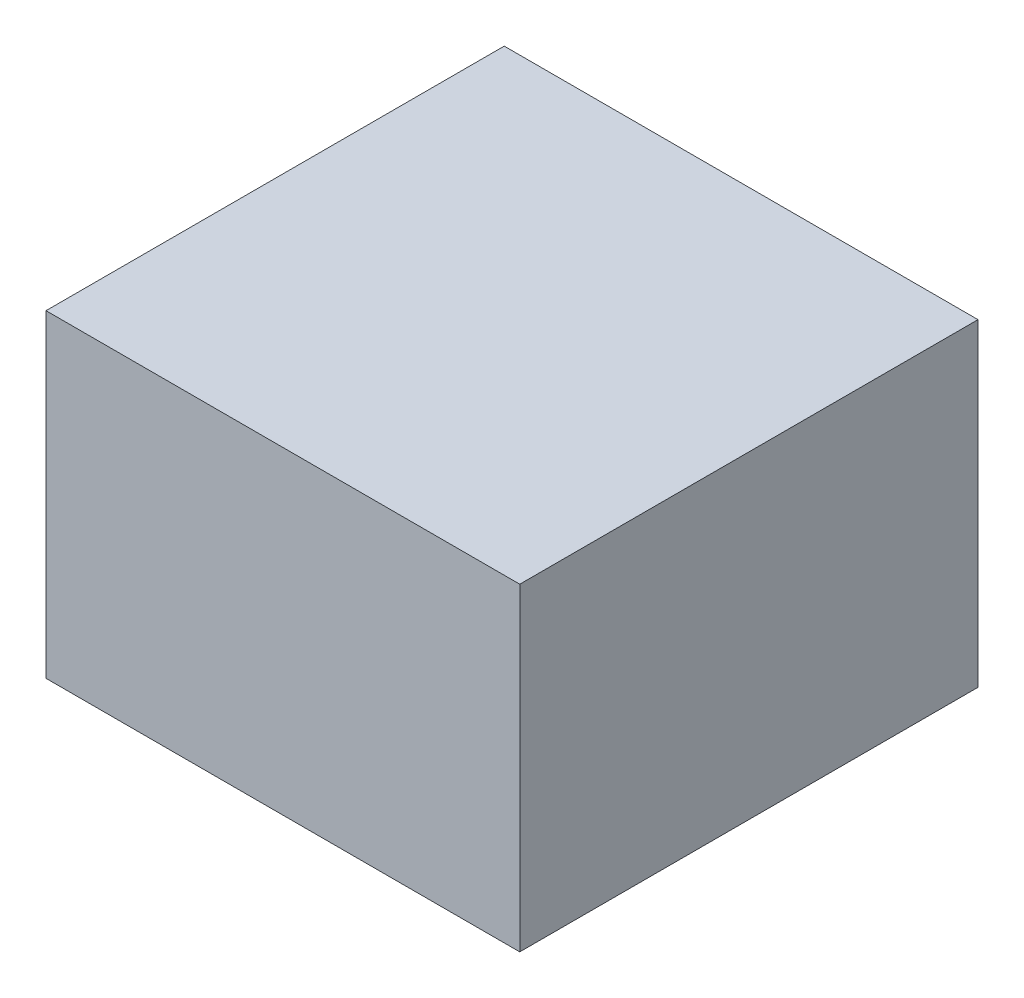
from build123d import *

# Parameters (mm, degrees)
SKETCH1_W           = 15.494
SKETCH1_H           = 10.414
BOSS_EXTRUDE1_DEPTH = 14.986


with BuildPart() as part:
    # Sketch1 → Boss-Extrude1 (new body)
    with BuildSketch(Plane.XY):
        Rectangle(SKETCH1_W, SKETCH1_H)
    extrude(amount=BOSS_EXTRUDE1_DEPTH)


solid = part.part
